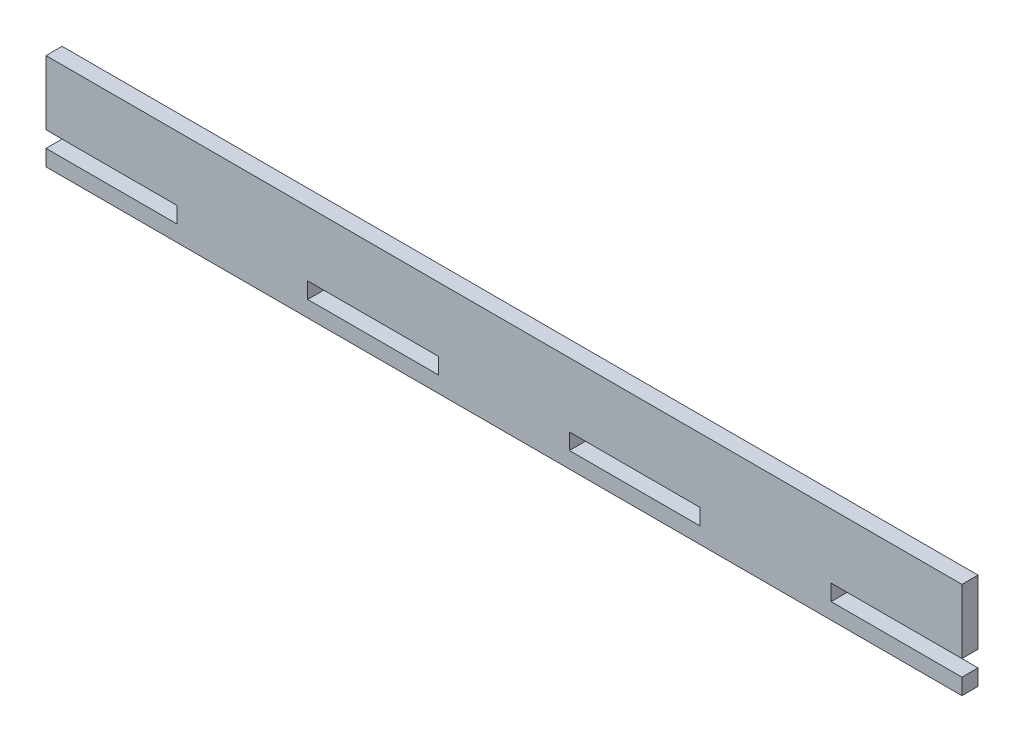
from build123d import *

# Parameters (mm, degrees)
ESQUISSE1_W        = 40.714285714
ESQUISSE1_H        = 5
BOSS_EXTRU_1_DEPTH = 5


with BuildPart() as part:
    # Esquisse1 → Boss.-Extru.1 (new body)
    with BuildSketch(Plane.XY):
        Polygon((0, 10), (0, 30), (285, 30), (285, 10), (244.285714286, 10), (244.285714286, 5), (285, 5), (285, 0), (0, 0), (0, 5), (40.714285714, 5), (40.714285714, 10), align=None)
        with Locations((101.785714286, 7.5)):
            Rectangle(ESQUISSE1_W, ESQUISSE1_H, mode=Mode.SUBTRACT)
        with Locations((183.214285714, 7.5)):
            Rectangle(ESQUISSE1_W, ESQUISSE1_H, mode=Mode.SUBTRACT)
    extrude(amount=BOSS_EXTRU_1_DEPTH)


solid = part.part
